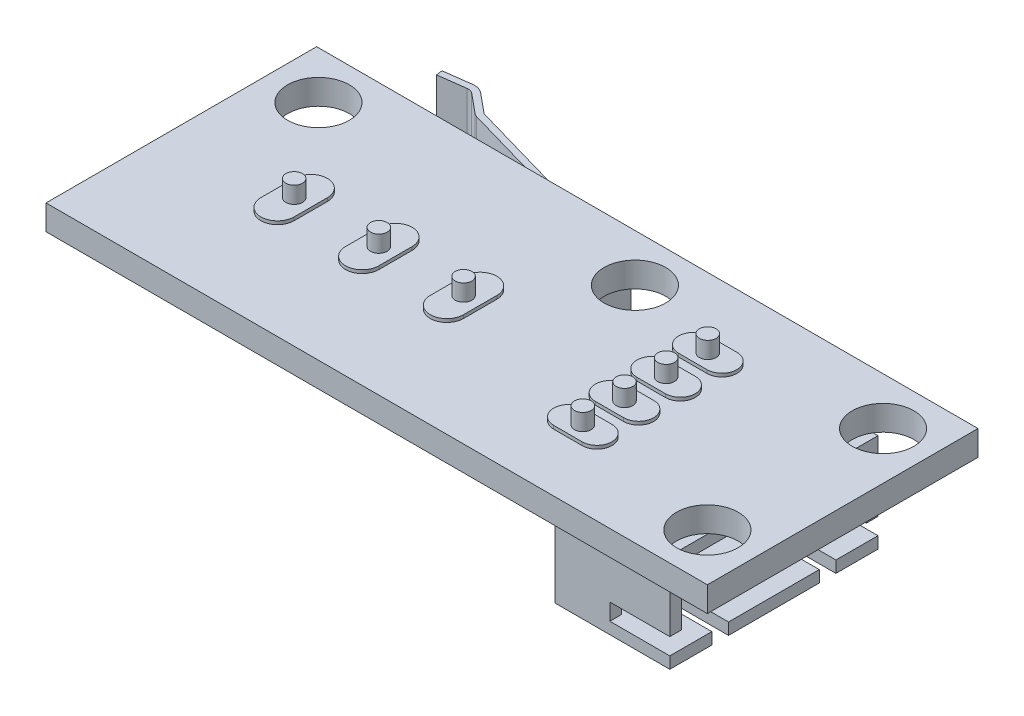
from build123d import *

# Parameters (mm, degrees)
SKETCH1_W           = 39.71
SKETCH1_H           = 16.25
SKETCH1_R           = 1.85
BOSS_EXTRUDE1_DEPTH = 1.5
SKETCH2_W           = 6.9
SKETCH2_H           = 12.5
BOSS_EXTRUDE2_DEPTH = 5.9
CUT_EXTRUDE1_DEPTH  = 5
SKETCH3_3_W         = 0.7
SKETCH3_3_H         = 1
SKETCH3_3_W_2       = 1
SKETCH3_3_H_2       = 0.7
CUT_EXTRUDE2_DEPTH  = 3.6
BOSS_EXTRUDE3_DEPTH = 5.75
SKETCH6_R           = 1.075
CUT_EXTRUDE3_DEPTH  = 5.75
SKETCH4_3_W         = 0.83
SKETCH4_3_H         = 2.45
BOSS_EXTRUDE4_DEPTH = 3.25
CUT_EXTRUDE4_DEPTH  = 11
BOSS_EXTRUDE5_DEPTH = 2.07
SKETCH11_R          = 0.5
BOSS_EXTRUDE6_DEPTH = 1.2
SKETCH11_3_R        = 0.5
BOSS_EXTRUDE7_DEPTH = 0.2


with BuildPart() as part:
    # Sketch1 → Boss-Extrude1 (new body)
    with BuildSketch(Plane(origin=(0, 0, 0), x_dir=(1, 0, 0), z_dir=(0, 1, 0))):
        Rectangle(SKETCH1_W, SKETCH1_H)
        with Locations((17.005, 5.275)):
            Circle(SKETCH1_R, mode=Mode.SUBTRACT)
        with Locations((17.005, -5.275)):
            Circle(SKETCH1_R, mode=Mode.SUBTRACT)
        with Locations((2.105, 5.275)):
            Circle(SKETCH1_R, mode=Mode.SUBTRACT)
        with Locations((-16.895, 5.275)):
            Circle(SKETCH1_R, mode=Mode.SUBTRACT)
    extrude(amount=BOSS_EXTRUDE1_DEPTH)

    # Sketch2 → Boss-Extrude2 (add)
    with BuildSketch(Plane.XZ):
        with Locations((12.275, 0)):
            Rectangle(SKETCH2_W, SKETCH2_H)
    extrude(amount=BOSS_EXTRUDE2_DEPTH)

    # Sketch3 → Cut-Extrude1 (cut)
    with BuildSketch(Plane(origin=(15.725, 0, 0), x_dir=(0, 0, -1), z_dir=(1, 0, 0))):
        Polygon((5.55, -0.7), (3.939297937, -0.7), (-3.939297937, -0.7), (-5.55, -0.7), (-5.55, -5.2), (5.55, -5.2), align=None)
    extrude(amount=-CUT_EXTRUDE1_DEPTH, mode=Mode.SUBTRACT)

    # Sketch3_3 → Cut-Extrude2 (cut)
    with BuildSketch(Plane(origin=(15.725, 0, 0), x_dir=(0, 0, -1), z_dir=(1, 0, 0))):
        with Locations((-5.9, -4.7)):
            Rectangle(SKETCH3_3_W, SKETCH3_3_H)
        with Locations((-3.225, -5.55)):
            Rectangle(SKETCH3_3_W_2, SKETCH3_3_H_2)
        with Locations((3.225, -5.55)):
            Rectangle(SKETCH3_3_W_2, SKETCH3_3_H_2)
        with Locations((5.9, -4.7)):
            Rectangle(SKETCH3_3_W, SKETCH3_3_H)
    extrude(amount=-CUT_EXTRUDE2_DEPTH, mode=Mode.SUBTRACT)

    # Sketch4 → Boss-Extrude3 (add)
    with BuildSketch(Plane.XZ):
        Polygon((-12.895, -1.575), (-13.825, -1.575), (-13.825, -8.125), (-0.965, -8.125), (-0.965, -1.575), (-1.895, -1.575), (-2.725, -1.575), (-6.98, -1.575), (-7.81, -1.575), (-12.065, -1.575), align=None)
    extrude(amount=BOSS_EXTRUDE3_DEPTH)

    # Sketch6 → Cut-Extrude3 (cut)
    with BuildSketch(Plane.XZ.offset(5.75)):
        with Locations((-10.595, -2.975)):
            Circle(SKETCH6_R)
        with Locations((-4.195, -2.975)):
            Circle(SKETCH6_R)
    extrude(amount=-CUT_EXTRUDE3_DEPTH, mode=Mode.SUBTRACT)

    # Sketch4_3 → Boss-Extrude4 (add)
    with BuildSketch(Plane.XZ):
        with Locations((-12.48, -0.35)):
            Rectangle(SKETCH4_3_W, SKETCH4_3_H)
        with Locations((-7.395, -0.35)):
            Rectangle(SKETCH4_3_W, SKETCH4_3_H)
        with Locations((-2.31, -0.35)):
            Rectangle(SKETCH4_3_W, SKETCH4_3_H)
    extrude(amount=BOSS_EXTRUDE4_DEPTH)

    # Sketch9 → Cut-Extrude4 (cut)
    with BuildSketch(Plane.ZY.offset(12.895)):
        with BuildLine():
            Line((-1.575, 0), (0.325, 0))
            Line((0.325, 0), (0.325, -2.6))
            ThreePointArc((0.325, -2.6), (0.295710678, -2.670710678), (0.225, -2.7))
            Line((0.225, -2.7), (-1.575, -2.7))
            Line((-1.575, -2.7), (-1.575, 0))
        make_face()
        with BuildLine():
            Line((0.875, -2.6), (0.875, -3.25))
            Line((0.875, -3.25), (0.225, -3.25))
            ThreePointArc((0.225, -3.25), (0.684619408, -3.059619408), (0.875, -2.6))
        make_face()
    extrude(amount=-CUT_EXTRUDE4_DEPTH, mode=Mode.SUBTRACT)

    # Sketch10 → Boss-Extrude5 (add, symmetric)
    with BuildSketch(Plane(origin=(0, -2.875, 0), x_dir=(-1, 0, 0), z_dir=(0, -1, 0))):
        with BuildLine():
            Line((1.965, 8.125), (1.965, 8.225))
            Line((1.965, 8.225), (13.72492529, 11.596310791))
            ThreePointArc((13.72492529, 11.596310791), (13.820005869, 11.634489053), (13.905307898, 11.691246962))
            Line((13.905307898, 11.691246962), (15.087352442, 12.666329881))
            ThreePointArc((15.087352442, 12.666329881), (15.26773505, 12.761266052), (15.471018562, 12.776318482))
            Line((15.471018562, 12.776318482), (17.093348193, 12.561963226))
            Line((17.093348193, 12.561963226), (17.143124243, 12.938689048))
            Line((17.143124243, 12.938689048), (15.520794612, 13.153044304))
            ThreePointArc((15.520794612, 13.153044304), (15.163015631, 13.126552026), (14.84554224, 12.959464366))
            Line((14.84554224, 12.959464366), (13.663497696, 11.984381447))
            ThreePointArc((13.663497696, 11.984381447), (13.643025209, 11.970759549), (13.62020587, 11.961596766))
            Line((13.62020587, 11.961596766), (1.585, 8.511369113))
            Line((1.585, 8.511369113), (1.585, 8.125))
            Line((1.585, 8.125), (1.965, 8.125))
        make_face()
    extrude(amount=BOSS_EXTRUDE5_DEPTH, both=True)

    # Sketch11 → Boss-Extrude6 (add)
    with BuildSketch(Plane(origin=(0, 1.5, 0), x_dir=(1, 0, 0), z_dir=(0, 1, 0))):
        with Locations((-12.48, -0.6)):
            Circle(SKETCH11_R)
        with Locations((-7.395, -0.6)):
            Circle(SKETCH11_R)
        with Locations((-2.31, -0.6)):
            Circle(SKETCH11_R)
        with Locations((8.005, 3.75)):
            Circle(SKETCH11_R)
        with Locations((8.005, 1.25)):
            Circle(SKETCH11_R)
        with Locations((8.005, -1.25)):
            Circle(SKETCH11_R)
        with Locations((8.005, -3.75)):
            Circle(SKETCH11_R)
    extrude(amount=BOSS_EXTRUDE6_DEPTH)

    # Sketch11_3 → Boss-Extrude7 (add)
    with BuildSketch(Plane(origin=(0, 1.5, 0), x_dir=(1, 0, 0), z_dir=(0, 1, 0))):
        with BuildLine():
            Line((-13.48, -1.6), (-13.48, 0.4))
            ThreePointArc((-13.48, 0.4), (-12.48, 1.4), (-11.48, 0.4))
            Line((-11.48, 0.4), (-11.48, -1.6))
            ThreePointArc((-11.48, -1.6), (-12.48, -2.6), (-13.48, -1.6))
        make_face()
        with Locations((-12.48, -0.6)):
            Circle(SKETCH11_3_R, mode=Mode.SUBTRACT)
        with BuildLine():
            Line((-8.395, -1.6), (-8.395, 0.4))
            ThreePointArc((-8.395, 0.4), (-7.395, 1.4), (-6.395, 0.4))
            Line((-6.395, 0.4), (-6.395, -1.6))
            ThreePointArc((-6.395, -1.6), (-7.395, -2.6), (-8.395, -1.6))
        make_face()
        with Locations((-7.395, -0.6)):
            Circle(SKETCH11_3_R, mode=Mode.SUBTRACT)
        with BuildLine():
            Line((-3.31, -1.6), (-3.31, 0.4))
            ThreePointArc((-3.31, 0.4), (-2.31, 1.4), (-1.31, 0.4))
            Line((-1.31, 0.4), (-1.31, -1.6))
            ThreePointArc((-1.31, -1.6), (-2.31, -2.6), (-3.31, -1.6))
        make_face()
        with Locations((-2.31, -0.6)):
            Circle(SKETCH11_3_R, mode=Mode.SUBTRACT)
        with BuildLine():
            Line((7.155, 4.65), (8.855, 4.65))
            ThreePointArc((8.855, 4.65), (9.755, 3.75), (8.855, 2.85))
            Line((8.855, 2.85), (7.155, 2.85))
            ThreePointArc((7.155, 2.85), (6.255, 3.75), (7.155, 4.65))
        make_face()
        with Locations((8.005, 3.75)):
            Circle(SKETCH11_3_R, mode=Mode.SUBTRACT)
        with BuildLine():
            Line((7.155, 2.15), (8.855, 2.15))
            ThreePointArc((8.855, 2.15), (9.755, 1.25), (8.855, 0.35))
            Line((8.855, 0.35), (7.155, 0.35))
            ThreePointArc((7.155, 0.35), (6.255, 1.25), (7.155, 2.15))
        make_face()
        with Locations((8.005, 1.25)):
            Circle(SKETCH11_3_R, mode=Mode.SUBTRACT)
        with BuildLine():
            Line((7.155, -0.35), (8.855, -0.35))
            ThreePointArc((8.855, -0.35), (9.755, -1.25), (8.855, -2.15))
            Line((8.855, -2.15), (7.155, -2.15))
            ThreePointArc((7.155, -2.15), (6.255, -1.25), (7.155, -0.35))
        make_face()
        with Locations((8.005, -1.25)):
            Circle(SKETCH11_3_R, mode=Mode.SUBTRACT)
        with BuildLine():
            Line((7.155, -2.85), (8.855, -2.85))
            ThreePointArc((8.855, -2.85), (9.755, -3.75), (8.855, -4.65))
            Line((8.855, -4.65), (7.155, -4.65))
            ThreePointArc((7.155, -4.65), (6.255, -3.75), (7.155, -2.85))
        make_face()
        with Locations((8.005, -3.75)):
            Circle(SKETCH11_3_R, mode=Mode.SUBTRACT)
    extrude(amount=BOSS_EXTRUDE7_DEPTH)


solid = part.part
